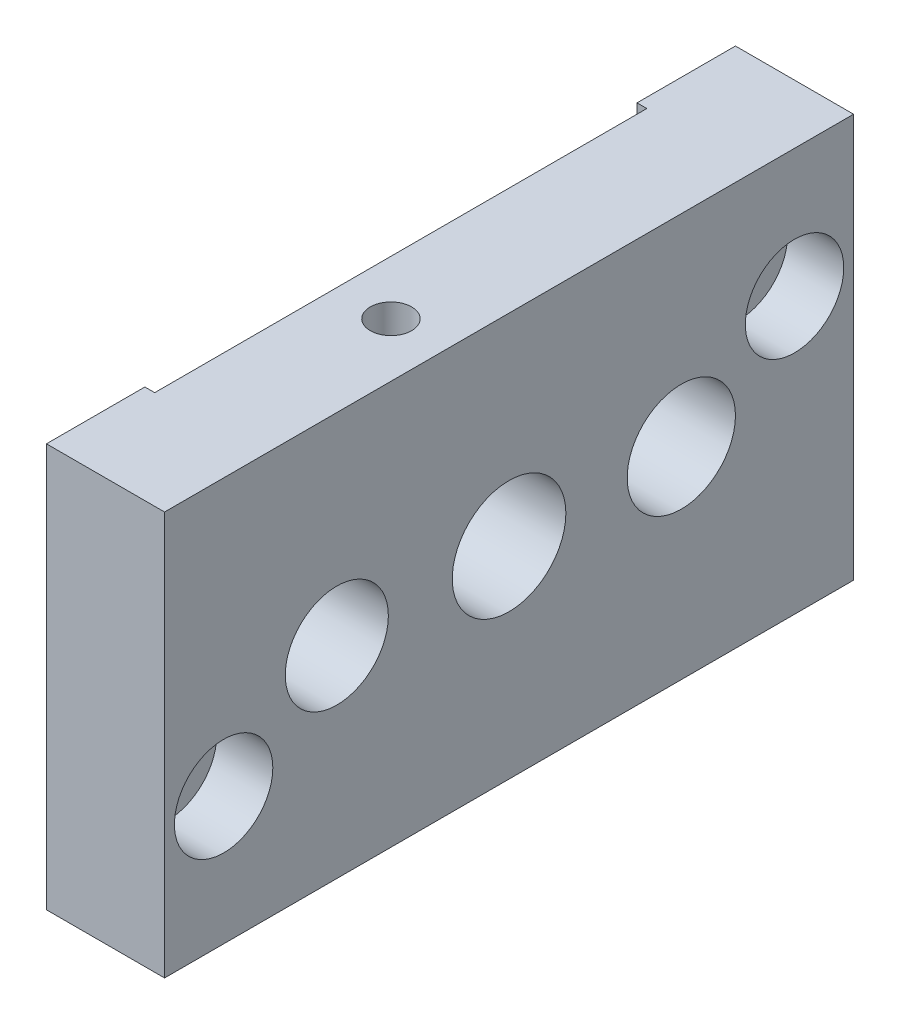
from build123d import *

# Parameters (mm, degrees)
BOSS_EXTRUDE1_DEPTH   = 41
SKETCH2_R             = 2.75
SKETCH2_R_2           = 5.237100589
SKETCH2_R_3           = 5.771252778
SKETCH2_R_4           = 5.5
CUT_EXTRUDE10_DEPTH   = 13
SKETCH11_R            = 5
CUT_EXTRUDE11_DEPTH   = 5.7
M5_TAPPED_HOLE1_D     = 4.2
M5_TAPPED_HOLE1_DEPTH = 12
M5_TAPPED_HOLE1_TIP   = 1.2618073


with BuildPart() as part:
    # Sketch1 → Boss-Extrude1 (new body)
    with BuildSketch(Plane(origin=(0, 0, 0), x_dir=(1, 0, 0), z_dir=(0, 1, 0))):
        Polygon((-6, 25), (-5, 25), (-5, -25), (-6, -25), (-6, -35), (6, -35), (6, 35), (-6, 35), align=None)
    extrude(amount=BOSS_EXTRUDE1_DEPTH)

    # Sketch2 → Cut-Extrude10 (cut, through all)
    with BuildSketch(Plane(origin=(6, 0, 0), x_dir=(0, 0, -1), z_dir=(1, 0, 0))):
        with Locations((29, 28)):
            Circle(SKETCH2_R)
        with Locations((-17.5, 20.5)):
            Circle(SKETCH2_R_2)
        with Locations((0, 20.5)):
            Circle(SKETCH2_R_3)
        with Locations((17.5, 20.5)):
            Circle(SKETCH2_R_4)
        with Locations((-29, 13)):
            Circle(SKETCH2_R)
    extrude(amount=-CUT_EXTRUDE10_DEPTH, mode=Mode.SUBTRACT)

    # Sketch11 → Cut-Extrude11 (cut)
    with BuildSketch(Plane(origin=(6, 0, 0), x_dir=(0, 0, -1), z_dir=(1, 0, 0))):
        with Locations((29, 28)):
            Circle(SKETCH11_R)
        with Locations((-29, 13)):
            Circle(SKETCH11_R)
    extrude(amount=-CUT_EXTRUDE11_DEPTH, mode=Mode.SUBTRACT)

    # M5 Tapped Hole1
    with Locations(Plane(origin=(0, 41, 0), x_dir=(1, 0, 0), z_dir=(0, 1, 0))):
        with Locations((0.5, -6.5)):
            Hole(M5_TAPPED_HOLE1_D / 2, depth=M5_TAPPED_HOLE1_DEPTH)
            with Locations((0, 0, -(M5_TAPPED_HOLE1_DEPTH + M5_TAPPED_HOLE1_TIP / 2))):  # 118° drill point
                Cone(0, M5_TAPPED_HOLE1_D / 2, M5_TAPPED_HOLE1_TIP, mode=Mode.SUBTRACT)


solid = part.part
